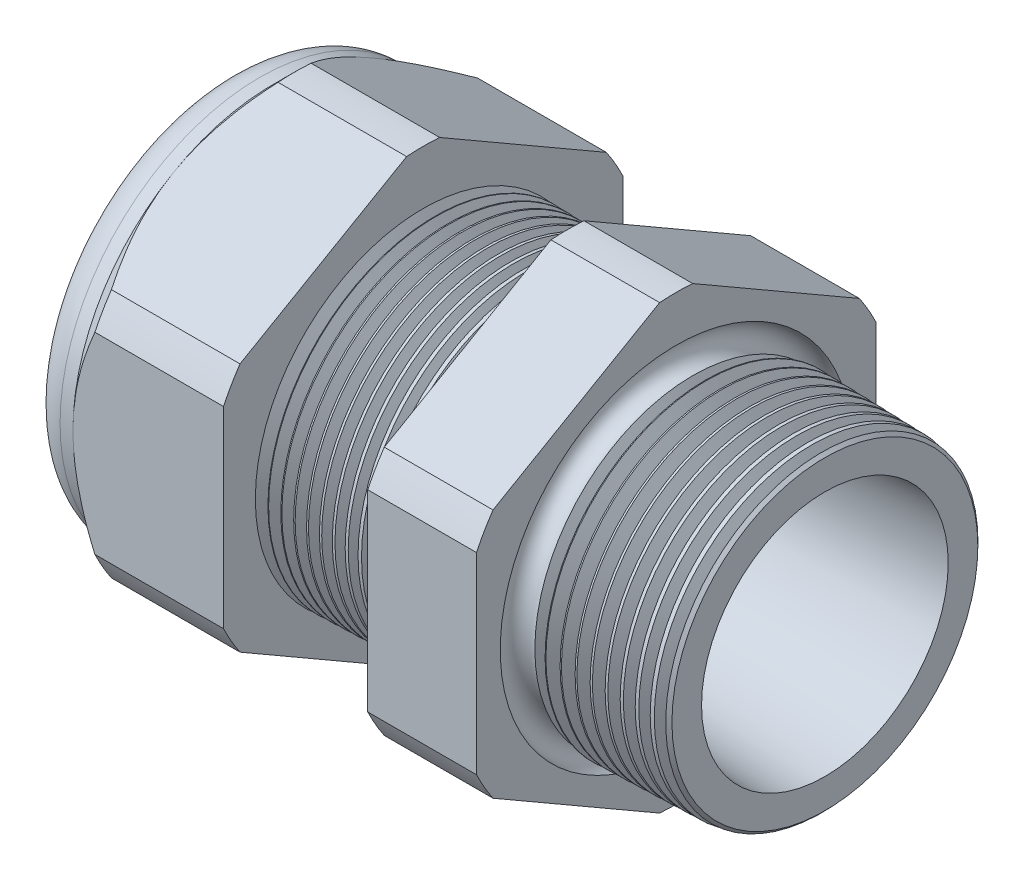
from build123d import *

# Parameters (mm, degrees)
SKETCH12_OUTSIDE_W = 65.04
SKETCH12_OUTSIDE_H = 65.04
CUT_EXTRUDE2_DEPTH = 34.014
FILLET4_R          = 2.032
SKETCH19_OUTSIDE_W = 39.986
SKETCH19_OUTSIDE_H = 42.612
SKETCH19_OUTSIDE_R = 11.938
CUT_EXTRUDE3_DEPTH = 1.999996
CUT_EXTRUDE3_DRAFT = -45
CHAMFER1_SIZE      = 0.260919487
CHAMFER1_SIZE2     = 0.254
SKETCH21_R         = 5.969
PLUG_DEPTH         = 6.35
SKETCH22_R         = 5.715
CUT_EXTRUDE4_DEPTH = 0.508
SKETCH27_R         = 1.016
PLUGHOLES_DEPTH    = 36.306
CIRPATTERN1_COUNT  = 3
LPATTERN1_COUNT    = 11
LPATTERN1_PITCH    = 0.762
LPATTERN2_COUNT    = 10
LPATTERN2_PITCH    = 0.889
SKETCH32_R         = 0.889


with BuildPart() as part:
    # Sketch10 → Revolve2 (revolve)
    with BuildSketch(Plane.XY, mode=Mode.PRIVATE) as revolve2_sk:
        Polygon((-34.798, 5.969), (-22.998, 5.969), (1.016, 7.372171279), (1.016, 9.404171279), (-7.874, 9.636964122), (-7.874, 23.876), (-14.374, 23.876), (-14.374, 9.807172612), (-22.998, 10.033), (-22.998, 23.876), (-31.998, 23.876), (-31.998, 11.938), (-34.798, 11.938), align=None)
    revolve(revolve2_sk.sketch.rotate(Axis((0, 0, 0), (-1, 0, 0)), 90), axis=Axis((0, 0, 0), (-1, 0, 0)))  # turned: the seam where the file's is

    # Sketch12 outside → Cut-Extrude2 (cut, through all)
    with BuildSketch(Plane.ZY.offset(31.998)):
        Rectangle(SKETCH12_OUTSIDE_W, SKETCH12_OUTSIDE_H)
        with BuildLine():
            Line((-0.98819228, 13.214281948), (-10.94980772, 7.462940592))
            ThreePointArc((-10.94980772, 7.462940592), (-11.47585851, 6.62559), (-11.938, 5.751341356))
            Line((-11.938, 5.751341356), (-11.938, -5.751341356))
            ThreePointArc((-11.938, -5.751341356), (-11.47585851, -6.62559), (-10.94980772, -7.462940592))
            Line((-10.94980772, -7.462940592), (-0.98819228, -13.214281948))
            ThreePointArc((-0.98819228, -13.214281948), (0, -13.25118), (0.98819228, -13.214281948))
            Line((0.98819228, -13.214281948), (10.94980772, -7.462940592))
            ThreePointArc((10.94980772, -7.462940592), (11.47585851, -6.62559), (11.938, -5.751341356))
            Line((11.938, -5.751341356), (11.938, 5.751341356))
            ThreePointArc((11.938, 5.751341356), (11.47585851, 6.62559), (10.94980772, 7.462940592))
            Line((10.94980772, 7.462940592), (0.98819228, 13.214281948))
            ThreePointArc((0.98819228, 13.214281948), (0, 13.25118), (-0.98819228, 13.214281948))
        make_face(mode=Mode.SUBTRACT)
    extrude(amount=-CUT_EXTRUDE2_DEPTH, mode=Mode.SUBTRACT)

    # Fillet4
    fillet4_edges = [part.edges().sort_by_distance(p)[0] for p in [
        (-34.798, 0, 11.938),
    ]]
    fillet(fillet4_edges, radius=FILLET4_R)


with BuildPart() as cut_extrude3_tool:
    # Sketch19 outside → Cut-Extrude3 (with draft: the straight prism first)
    with BuildSketch(Plane.ZY.offset(31.998)):
        Rectangle(SKETCH19_OUTSIDE_W, SKETCH19_OUTSIDE_H)
        Circle(SKETCH19_OUTSIDE_R, mode=Mode.SUBTRACT)
    extrude(amount=-CUT_EXTRUDE3_DEPTH)
    # Cut-Extrude3: the draft: its side faces are tilted about the plane it starts from
    cut_extrude3_sides = [cut_extrude3_tool.faces().sort_by_distance(p)[0] for p in [
        (-30.998002, -21.306, 0),
        (-30.998002, 0, 19.993),
        (-30.998002, 21.306, 0),
        (-30.998002, 0, -19.993),
        (-30.998002, 0, -11.938),
    ]]
    draft(cut_extrude3_sides, Plane.ZY.offset(31.998), CUT_EXTRUDE3_DRAFT)


with BuildPart() as part_1:
    add(part.part)

    # Cut-Extrude3: cut by cut_extrude3_tool
    add(cut_extrude3_tool.part, mode=Mode.SUBTRACT)

    # Chamfer1
    chamfer1_edges = [part_1.edges().sort_by_distance(p)[0] for p in [
        (1.016, 0, 9.404171279),
    ]]
    chamfer1_side = [part_1.faces().sort_by_distance(p)[0] for p in [
        (1.016, 0, 7.638161411),
    ]]
    chamfer(chamfer1_edges, length=CHAMFER1_SIZE, length2=CHAMFER1_SIZE2, reference=chamfer1_side[0])

    # Sketch29 → Cut-Revolve1 (revolve, cut)
    with BuildSketch(Plane.XY, mode=Mode.PRIVATE) as cut_revolve1_sk:
        Polygon((-22.998, 10.033), (-22.265016419, 10.013806149), (-22.648130572, 9.388620673), align=None)
    cut_revolve1 = revolve(cut_revolve1_sk.sketch.rotate(Axis((0, 0, 0), (-1, 0, 0)), 90), axis=Axis((0, 0, 0), (-1, 0, 0)), mode=Mode.SUBTRACT)  # turned: the seam where the file's is

    # LPattern1: Cut-Revolve1 ×11
    with Locations(*[(i * LPATTERN1_PITCH, 0, 0) for i in range(1, LPATTERN1_COUNT)]):
        add(cut_revolve1, mode=Mode.SUBTRACT)

    # Sketch30 → Cut-Revolve2 (revolve, cut)
    with BuildSketch(Plane.XY, mode=Mode.PRIVATE) as cut_revolve2_sk:
        Polygon((-7.874, 9.636964122), (-6.994419703, 9.613931502), (-7.454156686, 8.86370893), align=None)
    cut_revolve2 = revolve(cut_revolve2_sk.sketch.rotate(Axis((0, 0, 0), (-1, 0, 0)), 270), axis=Axis((0, 0, 0), (-1, 0, 0)), mode=Mode.SUBTRACT)  # turned: the seam where the file's is

    # LPattern2: Cut-Revolve2 ×10
    with Locations(*[(i * LPATTERN2_PITCH, 0, 0) for i in range(1, LPATTERN2_COUNT)]):
        add(cut_revolve2, mode=Mode.SUBTRACT)

    # Sketch32 → Cut-Revolve3 (revolve, cut)
    with BuildSketch(Plane.XY, mode=Mode.PRIVATE) as cut_revolve3_sk:
        with Locations((-7.747, 9.636964122)):
            Circle(SKETCH32_R)
    revolve(cut_revolve3_sk.sketch.rotate(Axis((0, 0, 0), (-1, 0, 0)), 270), axis=Axis((0, 0, 0), (-1, 0, 0)), mode=Mode.SUBTRACT)  # turned: the seam where the file's is


with BuildPart() as body_2:
    # Sketch21 → plug (new body)
    with BuildSketch(Plane.ZY.offset(34.798)):
        Circle(SKETCH21_R)
    extrude(amount=-PLUG_DEPTH)

    # Sketch22 → Cut-Extrude4 (cut)
    with BuildSketch(Plane.ZY.offset(34.798)):
        Circle(SKETCH22_R)
    extrude(amount=-CUT_EXTRUDE4_DEPTH, mode=Mode.SUBTRACT)

    # Sketch27 → plugholes (cut, through all)
    with BuildSketch(Plane.ZY.offset(34.29)):
        with Locations((-4.694936, 0)):
            Circle(SKETCH27_R)
    plugholes = extrude(amount=-PLUGHOLES_DEPTH, mode=Mode.SUBTRACT)

    # CirPattern1: plugholes ×3 about axis
    cirpattern1_axis = Axis((0, 0, 0), (1, 0, 0))
    for i in range(1, CIRPATTERN1_COUNT):
        add(plugholes.rotate(cirpattern1_axis, i * 360 / CIRPATTERN1_COUNT), mode=Mode.SUBTRACT)


solid = Compound([part_1.part, body_2.part])
